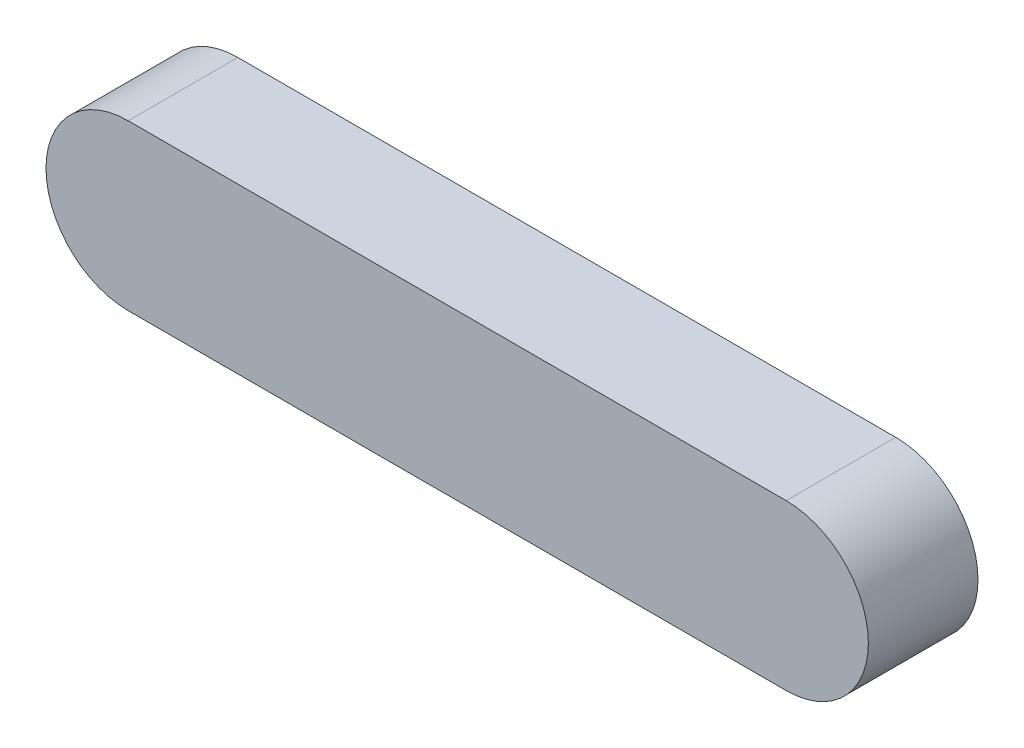
from build123d import *

# Parameters (mm, degrees)
EXTRUDE_1_DEPTH = 10


with BuildPart() as part:
    # 草图1 → 凸台-拉伸1 (new body)
    with BuildSketch(Plane.XY):
        with BuildLine():
            Line((0, -7.5), (-60, -7.5))
            ThreePointArc((-60, -7.5), (-67.5, 0), (-60, 7.5))
            Line((-60, 7.5), (0, 7.5))
            ThreePointArc((0, 7.5), (7.5, 0), (0, -7.5))
        make_face()
    extrude(amount=EXTRUDE_1_DEPTH)


solid = part.part
